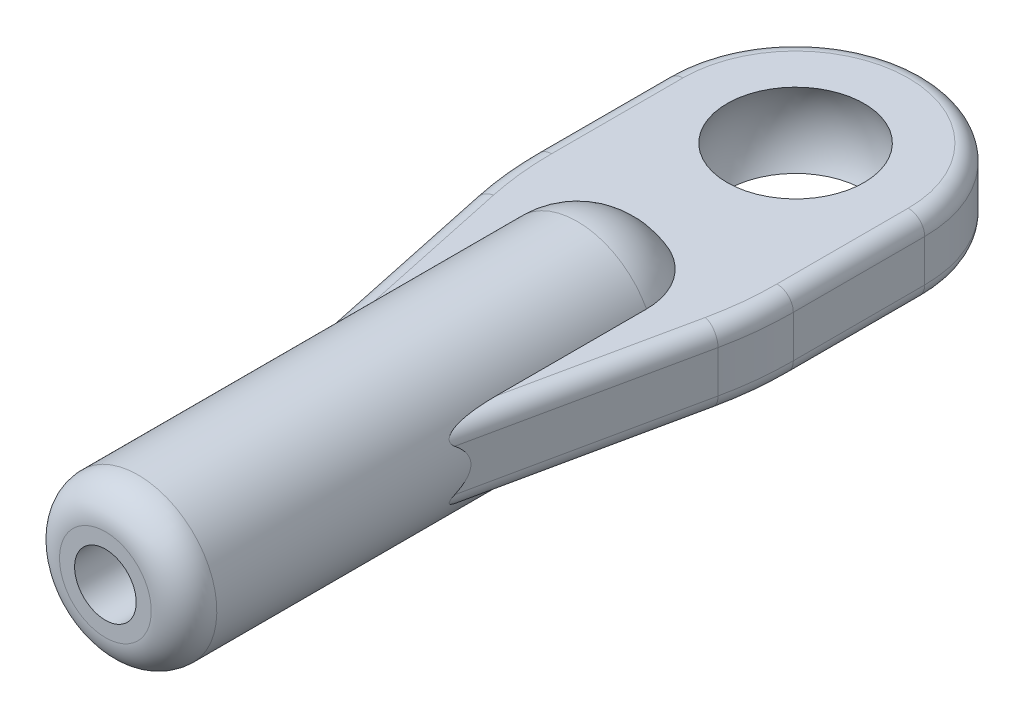
from build123d import *
from OCP.BRepFilletAPI import BRepFilletAPI_MakeFillet

# Parameters (mm, degrees)
FLAT_DEPTH = 1.14
FILLET2_R1 = 0.5
FILLET2_R2 = 1


with BuildPart() as part:
    # Sketch1 → Revolve1 (revolve)
    with BuildSketch(Plane(origin=(0, 0, 0), x_dir=(1, 0, 0), z_dir=(0, 1, 0))):
        with BuildLine():
            Line((0, 12.8), (0, 16.8))
            ThreePointArc((0, 16.8), (-1.697056275, 16.097056275), (-2.4, 14.4))
            Line((-2.4, 14.4), (-2.4, 0))
            Line((-2.4, 0), (-0.94, 0))
            Line((-0.94, 0), (-0.94, 12.8))
            Line((-0.94, 12.8), (0, 12.8))
        make_face()
    revolve(axis=Axis((0, 0, -12.8), (0, 0, -1)))

    # Sketch3 → Flat (add, symmetric)
    with BuildSketch(Plane(origin=(0, 0, 0), x_dir=(1, 0, 0), z_dir=(0, 1, 0))):
        with BuildLine():
            Line((3.721476007, 14.971925444), (0.94, 1.886109672))
            Line((0.94, 1.886109672), (0.94, 12.8))
            Line((0.94, 12.8), (-0.94, 12.8))
            Line((-0.94, 12.8), (-0.94, 1.886109672))
            Line((-0.94, 1.886109672), (-3.721476007, 14.971925444))
            ThreePointArc((-3.721476007, 14.971925444), (-3.885218954, 16.00575772), (-3.94, 17.051042353))
            Line((-3.94, 17.051042353), (-3.94, 21.06))
            ThreePointArc((-3.94, 21.06), (0, 25), (3.94, 21.06))
            Line((3.94, 21.06), (3.94, 17.051042353))
            ThreePointArc((3.94, 17.051042353), (3.885218954, 16.00575772), (3.721476007, 14.971925444))
        make_face()
    extrude(amount=FLAT_DEPTH, both=True)

    # Fillet2: one fillet with a radius per group of edges: ONE call of the kernel's fillet builder (fillet() takes one radius for all edges)
    fillet2_edges_1 = [part.edges().sort_by_distance(p)[0] for p in [
        (0, 1.14, -25),
        (0, -1.14, -25),
    ]]
    fillet2_edges_2 = [part.edges().sort_by_distance(p)[0] for p in [
        (2.4, 0, 0),
    ]]
    fillet2 = BRepFilletAPI_MakeFillet(part.part.solid().wrapped)
    for e in fillet2_edges_1:
        fillet2.Add(FILLET2_R1, e.wrapped)
    for e in fillet2_edges_2:
        fillet2.Add(FILLET2_R2, e.wrapped)
    add(Compound.cast(fillet2.Shape()), mode=Mode.REPLACE)

    # Sketch4 → Ball Hole (revolve, cut)
    with BuildSketch(Plane(origin=(0, 0, 0), x_dir=(1, 0, 0), z_dir=(0, 1, 0))):
        with BuildLine():
            Line((0, 23.44), (0, 18.68))
            ThreePointArc((0, 18.68), (2.38, 21.06), (0, 23.44))
        make_face()
    revolve(axis=Axis((0, 0, -23.44), (0, 0, 1)), mode=Mode.SUBTRACT)


solid = part.part
